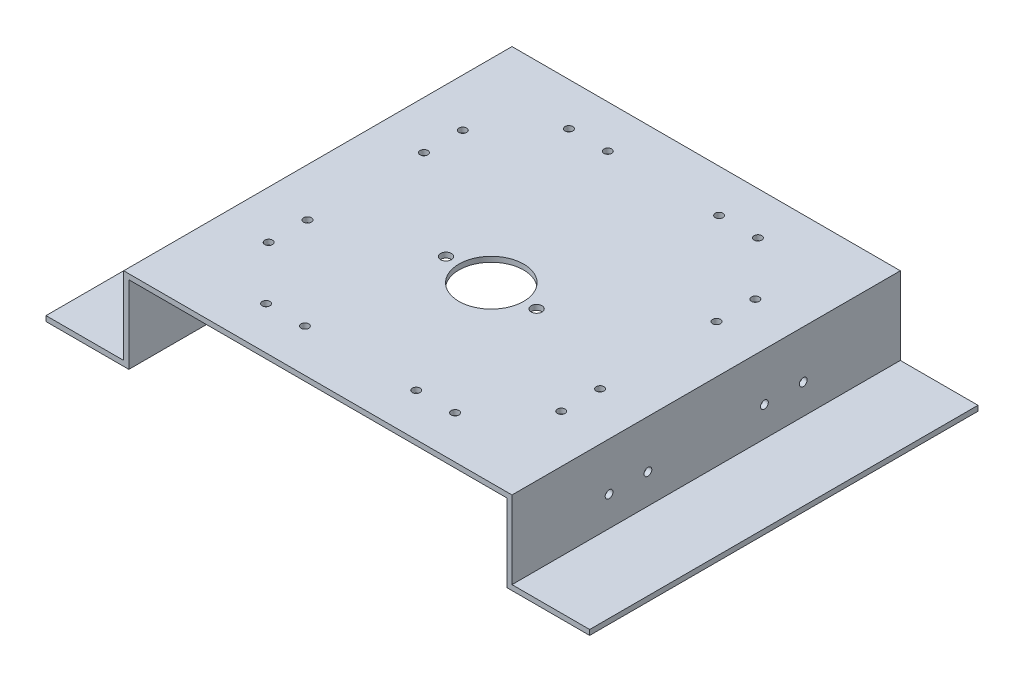
from build123d import *

# Parameters (mm, degrees)
BOSS_EXTRUDE1_DEPTH       = 150
CUT_EXTRUDE1_REACH        = 34
SKETCH2_R                 = 12.5
CUT_EXTRUDE2_REACH        = 34
SKETCH3_R                 = 2.1
F_3_0MM_DOWEL_HOLE1_D     = 3
F_3_0MM_DOWEL_HOLE1_DEPTH = 2
F_3_0MM_DOWEL_HOLE2_D     = 3
F_3_0MM_DOWEL_HOLE2_DEPTH = 2.001


with BuildPart() as part:
    # Sketch1 → Boss-Extrude1 (new body)
    with BuildSketch(Plane.XY):
        Polygon((-75, 16), (75, 16), (75, -14), (105, -14), (105, -16), (73, -16), (73, 14), (-73, 14), (-73, -16), (-105, -16), (-105, -14), (-75, -14), align=None)
    extrude(amount=-BOSS_EXTRUDE1_DEPTH)

    # Sketch2 → Cut-Extrude1 (cut, up to next)
    with BuildSketch(Plane(origin=(0, 16, 0), x_dir=(1, 0, 0), z_dir=(0, 1, 0)), mode=Mode.PRIVATE) as cut_extrude1_sk1:
        with Locations((0, 67)):
            Circle(SKETCH2_R)
    cut_extrude1_tool1 = extrude(cut_extrude1_sk1.sketch, amount=-CUT_EXTRUDE1_REACH, mode=Mode.PRIVATE) & part.part
    add(cut_extrude1_tool1.solids().sort_by_distance((0, 16, -67))[0], mode=Mode.SUBTRACT)

    # Sketch3 → Cut-Extrude2 (cut, up to next)
    with BuildSketch(Plane(origin=(0, 16, 0), x_dir=(1, 0, 0), z_dir=(0, 1, 0)), mode=Mode.PRIVATE) as cut_extrude2_sk1:
        with Locations((17.5, 67)):
            Circle(SKETCH3_R)
    cut_extrude2_tool1 = extrude(cut_extrude2_sk1.sketch, amount=-CUT_EXTRUDE2_REACH, mode=Mode.PRIVATE) & part.part
    add(cut_extrude2_tool1.solids().sort_by_distance((17.5, 16, -67))[0], mode=Mode.SUBTRACT)
    # Sketch3 → Cut-Extrude2 (cut, up to next)
    with BuildSketch(Plane(origin=(0, 16, 0), x_dir=(1, 0, 0), z_dir=(0, 1, 0)), mode=Mode.PRIVATE) as cut_extrude2_sk2:
        with Locations((-17.5, 67)):
            Circle(SKETCH3_R)
    cut_extrude2_tool2 = extrude(cut_extrude2_sk2.sketch, amount=-CUT_EXTRUDE2_REACH, mode=Mode.PRIVATE) & part.part
    add(cut_extrude2_tool2.solids().sort_by_distance((-17.5, 16, -67))[0], mode=Mode.SUBTRACT)

    # Ø3.0mm Dowel Hole1
    with Locations(Plane(origin=(0, 14, 0), x_dir=(-1, 0, 0), z_dir=(0, -1, 0))):
        with Locations((56.5, 97.5), (56.5, 112.5), (56.5, 52.5), (56.5, 37.5), (36.5, 16.5), (21.5, 16.5), (-21.5, 16.5), (-36.5, 16.5), (-56.5, 37.5), (-56.5, 52.5), (-56.5, 97.5), (-56.5, 112.5), (-36.5, 133.5), (-21.5, 133.5), (36.5, 133.5), (21.5, 133.5)):
            Hole(F_3_0MM_DOWEL_HOLE1_D / 2, depth=F_3_0MM_DOWEL_HOLE1_DEPTH)

    # Ø3.0mm Dowel Hole2
    with Locations(Plane.ZY.offset(-73)):
        with Locations((-112.5, -2.5), (-97.5, -2.5), (-52.5, -2.5), (-37.5, -2.5)):
            f_3_0mm_dowel_hole2 = Hole(F_3_0MM_DOWEL_HOLE2_D / 2, depth=F_3_0MM_DOWEL_HOLE2_DEPTH)

    # Mirror1: Ø3.0mm Dowel Hole2 across plane
    add(f_3_0mm_dowel_hole2.mirror(Plane(origin=(0, 0, 0), x_dir=(0, 0, 1), z_dir=(1, 0, 0))), mode=Mode.SUBTRACT)


solid = part.part
